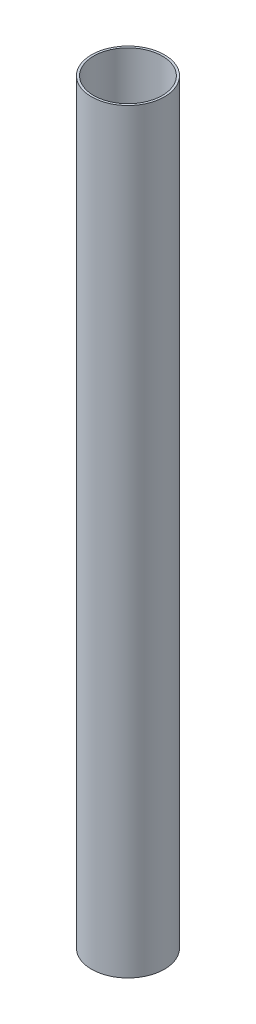
from build123d import *

# Parameters (mm, degrees)
SKETCH1_W = 3.175
SKETCH1_H = 1092.2


with BuildPart() as part:
    # Sketch1 → Revolve1 (revolve)
    with BuildSketch(Plane.XY):
        with Locations((51.1175, 546.1)):
            Rectangle(SKETCH1_W, SKETCH1_H)
    revolve(axis=Axis((0, 1146.81, 0), (0, -1, 0)))


solid = part.part
